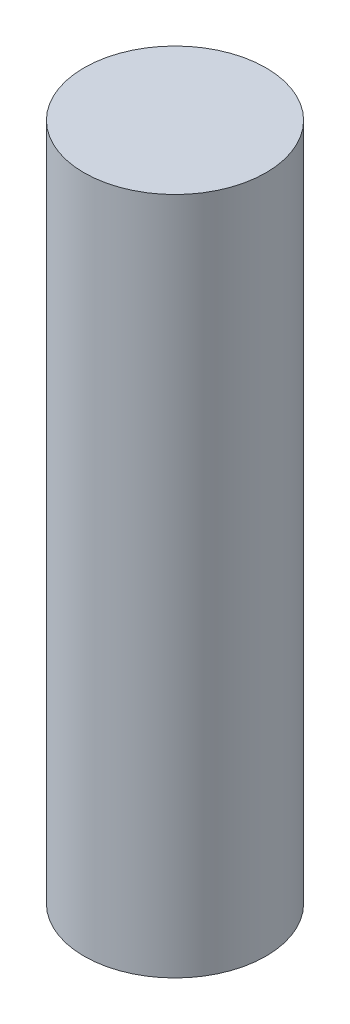
from build123d import *

# Parameters (mm, degrees)
SKETCH1_R           = 9.21
BOSS_EXTRUDE1_DEPTH = 68.7


with BuildPart() as part:
    # Sketch1 → Boss-Extrude1 (new body)
    with BuildSketch(Plane(origin=(0, 0, 0), x_dir=(1, 0, 0), z_dir=(0, 1, 0))):
        Circle(SKETCH1_R)
    extrude(amount=BOSS_EXTRUDE1_DEPTH)


solid = part.part
